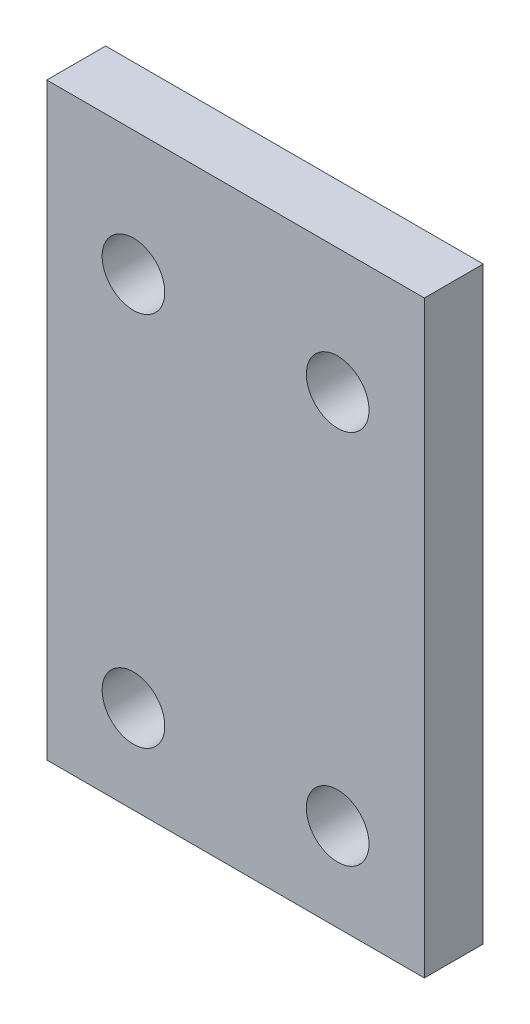
from build123d import *

# Parameters (mm, degrees)
SKETCH2_W           = 40.7162
SKETCH2_H           = 63.5
SKETCH2_R           = 3.3782
BOSS_EXTRUDE1_DEPTH = 6.35


with BuildPart() as part:
    # Sketch2 → Boss-Extrude1 (new body)
    with BuildSketch(Plane.XY):
        Rectangle(SKETCH2_W, SKETCH2_H)
        with Locations((11.0109, 18.288)):
            Circle(SKETCH2_R, mode=Mode.SUBTRACT)
        with Locations((11.0109, -22.225)):
            Circle(SKETCH2_R, mode=Mode.SUBTRACT)
        with Locations((-11.0109, -22.225)):
            Circle(SKETCH2_R, mode=Mode.SUBTRACT)
        with Locations((-11.0109, 18.288)):
            Circle(SKETCH2_R, mode=Mode.SUBTRACT)
    extrude(amount=BOSS_EXTRUDE1_DEPTH)


solid = part.part
